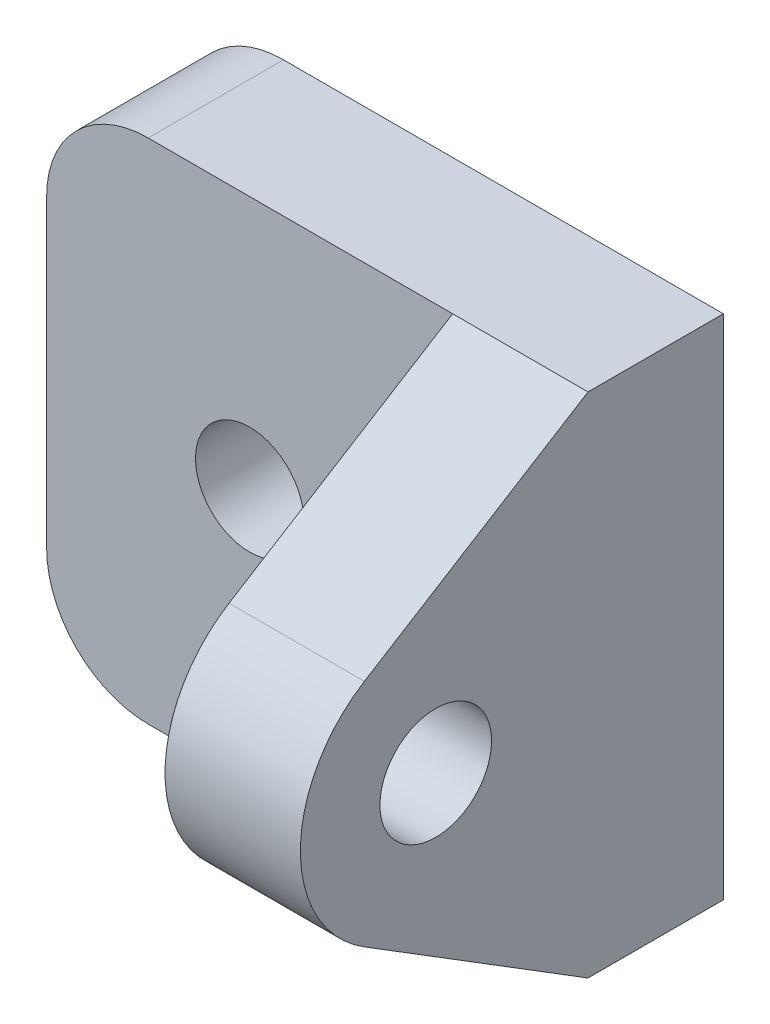
from build123d import *

# Parameters (mm, degrees)
SKETCH1_W           = 28
SKETCH1_H           = 15
BOSS_EXTRUDE1_DEPTH = 4
SKETCH3_R           = 4
SKETCH3_R_2         = 1.65
BOSS_EXTRUDE2_DEPTH = 4
SKETCH5_W           = 12
SKETCH5_H           = 15
SKETCH5_R           = 1.6
BOSS_EXTRUDE3_DEPTH = 4
FILLET1_R           = 3
CUT_EXTRUDE1_DEPTH  = 15


with BuildPart() as part:
    # Sketch1 → Boss-Extrude1 (new body)
    with BuildSketch(Plane.XY):
        Rectangle(SKETCH1_W, SKETCH1_H)
    extrude(amount=BOSS_EXTRUDE1_DEPTH)

    # Sketch3 → Boss-Extrude2 (add)
    with BuildSketch(Plane.ZY.offset(14)):
        with BuildLine():
            Line((10.609415807, 3.397699996), (4, 7.5))
            Line((4, 7.5), (4, -7.5))
            Line((4, -7.5), (10.608760269, -3.399872364))
            ThreePointArc((10.608760269, -3.399872364), (4.500000019, -0.000497042), (10.609415807, 3.397699996))
        make_face()
        with Locations((8.5, -0.00088279)):
            Circle(SKETCH3_R)
        with Locations((8.5, -0.00088279)):
            Circle(SKETCH3_R_2, mode=Mode.SUBTRACT)
    boss_extrude2 = extrude(amount=-BOSS_EXTRUDE2_DEPTH)

    # Sketch5 → Boss-Extrude3 (add)
    with BuildSketch(Plane(origin=(0, 0, 0), x_dir=(-1, 0, 0), z_dir=(0, 0, -1))):
        with Locations((20, 0)):
            Rectangle(SKETCH5_W, SKETCH5_H)
        with Locations((20, 0)):
            Circle(SKETCH5_R, mode=Mode.SUBTRACT)
    boss_extrude3 = extrude(amount=-BOSS_EXTRUDE3_DEPTH)

    # Mirror1: Boss-Extrude2, Boss-Extrude3 across plane
    add(boss_extrude2.mirror(Plane(origin=(0, 0, 0), x_dir=(0, 0, 1), z_dir=(1, 0, 0))))
    add(boss_extrude3.mirror(Plane(origin=(0, 0, 0), x_dir=(0, 0, 1), z_dir=(1, 0, 0))))

    # Fillet1
    fillet1_edges = [part.edges().sort_by_distance(p)[0] for p in [
        (-26, 7.5, 2),
        (-26, -7.5, 2),
        (26, 7.5, 2),
        (26, -7.5, 2),
    ]]
    fillet(fillet1_edges, radius=FILLET1_R)

    # Sketch6 → Cut-Extrude1 (cut)
    with BuildSketch(Plane.XZ.offset(7.5)):
        Polygon((0, 0), (37.280314588, 0), (37.280314588, 22.501925167), (0, 22.501925167), (-10, 22.501925167), (-10, 0), align=None)
    extrude(amount=-CUT_EXTRUDE1_DEPTH, mode=Mode.SUBTRACT)


solid = part.part
